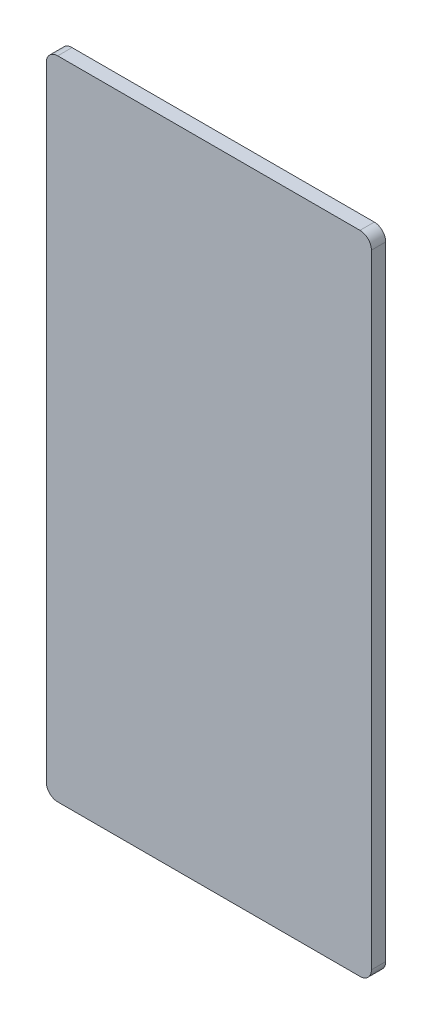
from build123d import *

# Parameters (mm, degrees)
SKETCH1_W           = 72.13854
SKETCH1_H           = 143.343173562
BOSS_EXTRUDE1_DEPTH = 3.175
FILLET1_R           = 2.54


with BuildPart() as part:
    # Sketch1 → Boss-Extrude1 (new body)
    with BuildSketch(Plane.XY):
        with Locations((36.06927, 71.671586781)):
            Rectangle(SKETCH1_W, SKETCH1_H)
    extrude(amount=BOSS_EXTRUDE1_DEPTH)

    # Fillet1
    fillet1_edges = [part.edges().sort_by_distance(p)[0] for p in [
        (0, 143.343173562, 1.5875),
        (72.13854, 143.343173562, 1.5875),
        (72.13854, 0, 1.5875),
        (0, 0, 1.5875),
    ]]
    fillet(fillet1_edges, radius=FILLET1_R)


solid = part.part
